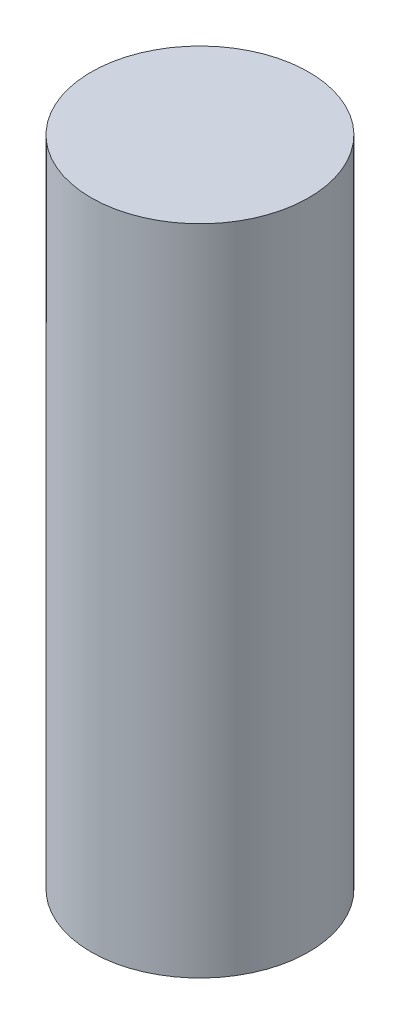
from build123d import *

# Parameters (mm, degrees)
SKETCH1_R           = 2.5
BOSS_EXTRUDE1_DEPTH = 15


with BuildPart() as part:
    # Sketch1 → Boss-Extrude1 (new body)
    with BuildSketch(Plane(origin=(0, 0, 0), x_dir=(1, 0, 0), z_dir=(0, 1, 0))):
        Circle(SKETCH1_R)
    extrude(amount=BOSS_EXTRUDE1_DEPTH)


solid = part.part
